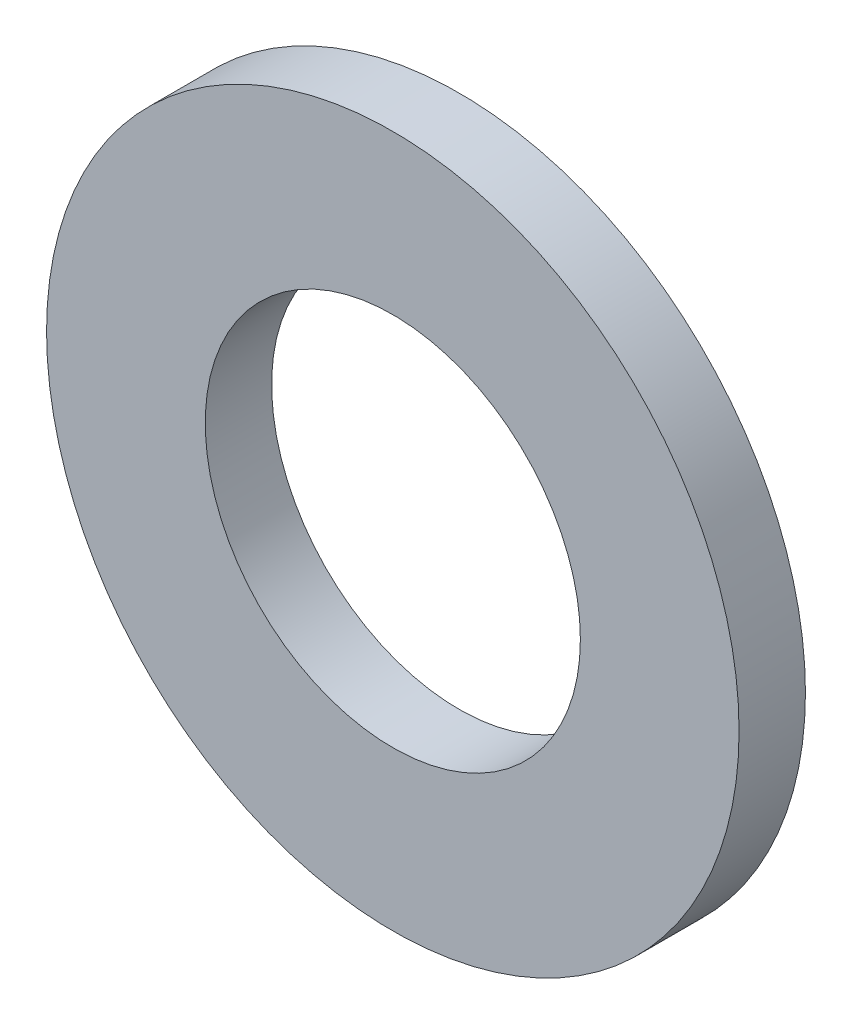
from build123d import *

# Parameters (mm, degrees)
SKETCH1_R      = 12
SKETCH1_R_2    = 6.5
EXTRUDE1_DEPTH = 2.3


with BuildPart() as part:
    # Sketch1 → Extrude1 (new body)
    with BuildSketch(Plane.XY):
        Circle(SKETCH1_R)
        Circle(SKETCH1_R_2, mode=Mode.SUBTRACT)
    extrude(amount=-EXTRUDE1_DEPTH)


solid = part.part
